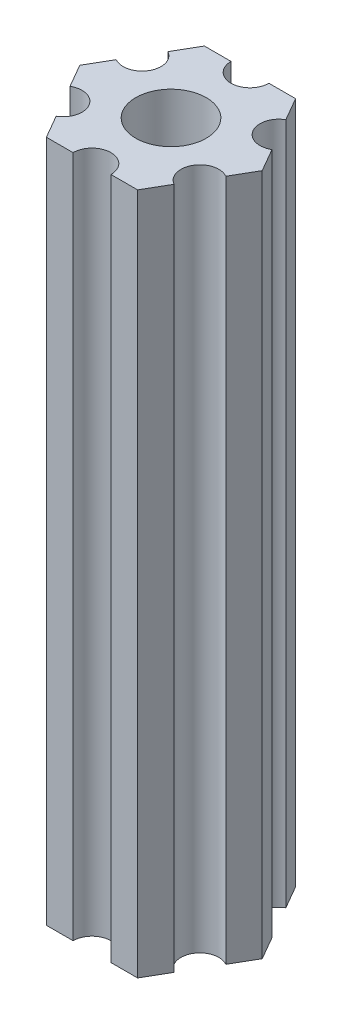
from build123d import *

# Parameters (mm, degrees)
ESBO_O1_R                = 2.79
RESSALTO_EXTRUS_O1_DEPTH = 54


with BuildPart() as part:
    # Esboço1 → Ressalto-extrusão1 (new body)
    with BuildSketch(Plane(origin=(0, 85, 0), x_dir=(1, 0, 0), z_dir=(0, 1, 0))):
        with BuildLine():
            Line((6.162658774, -1.825961894), (7.216878365, 0))
            Line((7.216878365, 0), (6.162658774, 1.825961894))
            ThreePointArc((6.162658774, 1.825961894), (4.113620668, 2.375), (4.662658774, 4.424038106))
            Line((4.662658774, 4.424038106), (3.608439182, 6.25))
            Line((3.608439182, 6.25), (1.5, 6.25))
            ThreePointArc((1.5, 6.25), (0, 4.75), (-1.5, 6.25))
            Line((-1.5, 6.25), (-3.608439182, 6.25))
            Line((-3.608439182, 6.25), (-4.662658774, 4.424038106))
            ThreePointArc((-4.662658774, 4.424038106), (-4.113620668, 2.375), (-6.162658774, 1.825961894))
            Line((-6.162658774, 1.825961894), (-7.216878365, 0))
            Line((-7.216878365, 0), (-6.162658774, -1.825961894))
            ThreePointArc((-6.162658774, -1.825961894), (-4.113620668, -2.375), (-4.662658774, -4.424038106))
            Line((-4.662658774, -4.424038106), (-3.608439182, -6.25))
            Line((-3.608439182, -6.25), (-1.5, -6.25))
            ThreePointArc((-1.5, -6.25), (0, -4.75), (1.5, -6.25))
            Line((1.5, -6.25), (3.608439182, -6.25))
            Line((3.608439182, -6.25), (4.662658774, -4.424038106))
            ThreePointArc((4.662658774, -4.424038106), (4.113620668, -2.375), (6.162658774, -1.825961894))
        make_face()
        Circle(ESBO_O1_R, mode=Mode.SUBTRACT)
    extrude(amount=-RESSALTO_EXTRUS_O1_DEPTH)


solid = part.part
